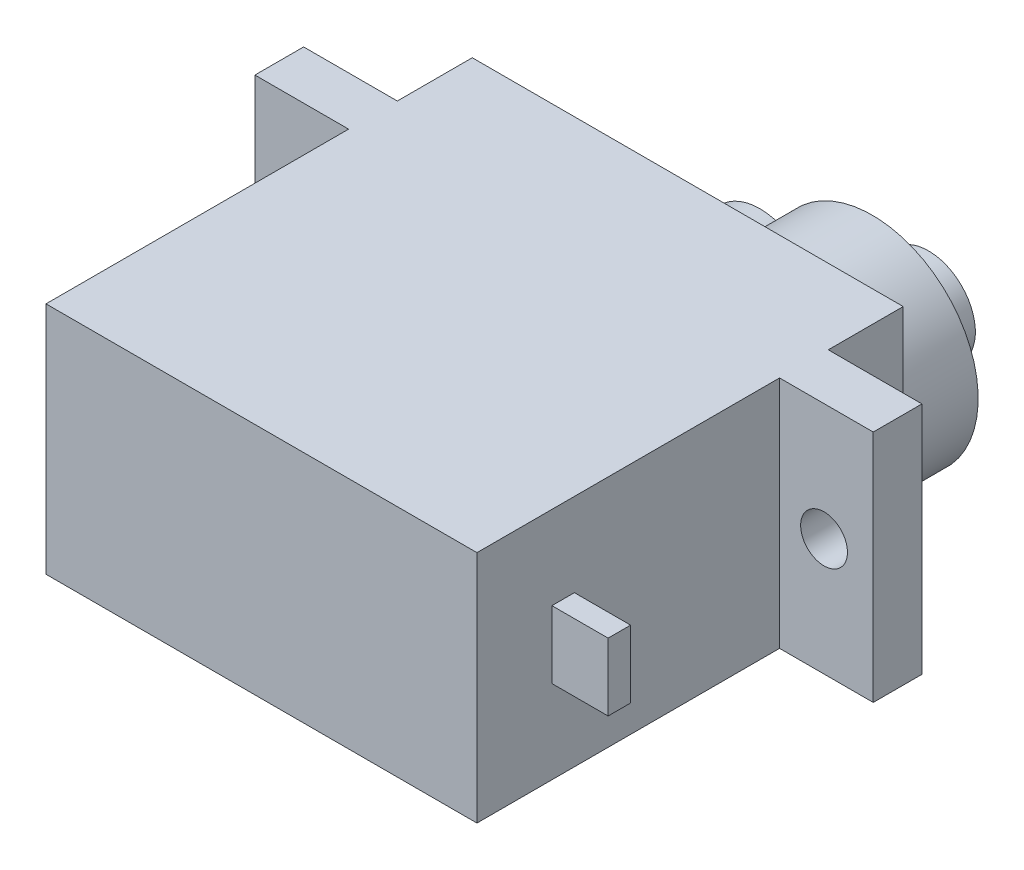
from build123d import *

# Parameters (mm, degrees)
SKETCH_1_W          = 5
SKETCH_1_H          = 2.6
SKETCH_1_W_2        = 23
SKETCH_1_H_2        = 22.75
EXTRUDE_1_DEPTH     = 12.5
SKETCH_2_R          = 5.65
EXTRUDE_2_DEPTH     = 4
SKETCH_3_R          = 2.5
EXTRUDE_3_DEPTH     = 3
SKETCH_4_R          = 0.9
CUT_EXTRUDE_1_DEPTH = 6.5
SKETCH_5_R          = 2.95
EXTRUDE_4_DEPTH     = 4
CUT_EXTRUDE_2_REACH = 20.75
SKETCH_6_R          = 1.25
SKETCH_7_W          = 1.2
SKETCH_7_H          = 3.6
EXTRUDE_5_DEPTH     = 3


with BuildPart() as part:
    # Эскиз1 → Бобышка-Вытянуть1 (new body)
    with BuildSketch(Plane(origin=(0, 0, 0), x_dir=(1, 0, 0), z_dir=(0, 1, 0))):
        with Locations((-2.5, 17.45)):
            Rectangle(SKETCH_1_W, SKETCH_1_H)
        with Locations((11.5, 11.375)):
            Rectangle(SKETCH_1_W_2, SKETCH_1_H_2)
        with Locations((25.5, 17.45)):
            Rectangle(SKETCH_1_W, SKETCH_1_H)
    extrude(amount=EXTRUDE_1_DEPTH)

    # Эскиз2 → Бобышка-Вытянуть2 (add)
    with BuildSketch(Plane(origin=(0, 0, -22.75), x_dir=(-1, 0, 0), z_dir=(0, 0, -1))):
        with Locations((-17.35, 6.25)):
            Circle(SKETCH_2_R)
    extrude(amount=EXTRUDE_2_DEPTH)

    # Эскиз3 → Бобышка-Вытянуть3 (add)
    with BuildSketch(Plane(origin=(0, 0, -26.75), x_dir=(-1, 0, 0), z_dir=(0, 0, -1))):
        with Locations((-17.35, 6.25)):
            Circle(SKETCH_3_R)
    extrude(amount=EXTRUDE_3_DEPTH)

    # Эскиз4 → Вырез-Вытянуть1 (cut)
    with BuildSketch(Plane(origin=(0, 0, -29.75), x_dir=(-1, 0, 0), z_dir=(0, 0, -1))):
        with Locations((-17.35, 6.25)):
            Circle(SKETCH_4_R)
    extrude(amount=-CUT_EXTRUDE_1_DEPTH, mode=Mode.SUBTRACT)

    # Эскиз5 → Бобышка-Вытянуть4 (add)
    with BuildSketch(Plane(origin=(0, 0, -22.75), x_dir=(-1, 0, 0), z_dir=(0, 0, -1))):
        with Locations((-11.35, 6.25)):
            Circle(SKETCH_5_R)
    extrude(amount=EXTRUDE_4_DEPTH)

    # Эскиз6 → Вырез-Вытянуть2 (cut, up to next)
    with BuildSketch(Plane(origin=(0, 0, -18.75), x_dir=(-1, 0, 0), z_dir=(0, 0, -1)), mode=Mode.PRIVATE) as cut_extrude_2_sk1:
        with Locations((2.375, 6.25)):
            Circle(SKETCH_6_R)
    cut_extrude_2_tool1 = extrude(cut_extrude_2_sk1.sketch, amount=-CUT_EXTRUDE_2_REACH, mode=Mode.PRIVATE) & part.part
    add(cut_extrude_2_tool1.solids().sort_by_distance((-2.375, 6.25, -18.75))[0], mode=Mode.SUBTRACT)
    # Эскиз6 → Вырез-Вытянуть2 (cut, up to next)
    with BuildSketch(Plane(origin=(0, 0, -18.75), x_dir=(-1, 0, 0), z_dir=(0, 0, -1)), mode=Mode.PRIVATE) as cut_extrude_2_sk2:
        with Locations((-25.375, 6.25)):
            Circle(SKETCH_6_R)
    cut_extrude_2_tool2 = extrude(cut_extrude_2_sk2.sketch, amount=-CUT_EXTRUDE_2_REACH, mode=Mode.PRIVATE) & part.part
    add(cut_extrude_2_tool2.solids().sort_by_distance((25.375, 6.25, -18.75))[0], mode=Mode.SUBTRACT)

    # Эскиз7 → Бобышка-Вытянуть5 (add)
    with BuildSketch(Plane(origin=(23, 0, 0), x_dir=(0, 0, -1), z_dir=(1, 0, 0))):
        with Locations((4.6, 6.25)):
            Rectangle(SKETCH_7_W, SKETCH_7_H)
    extrude(amount=EXTRUDE_5_DEPTH)


solid = part.part
